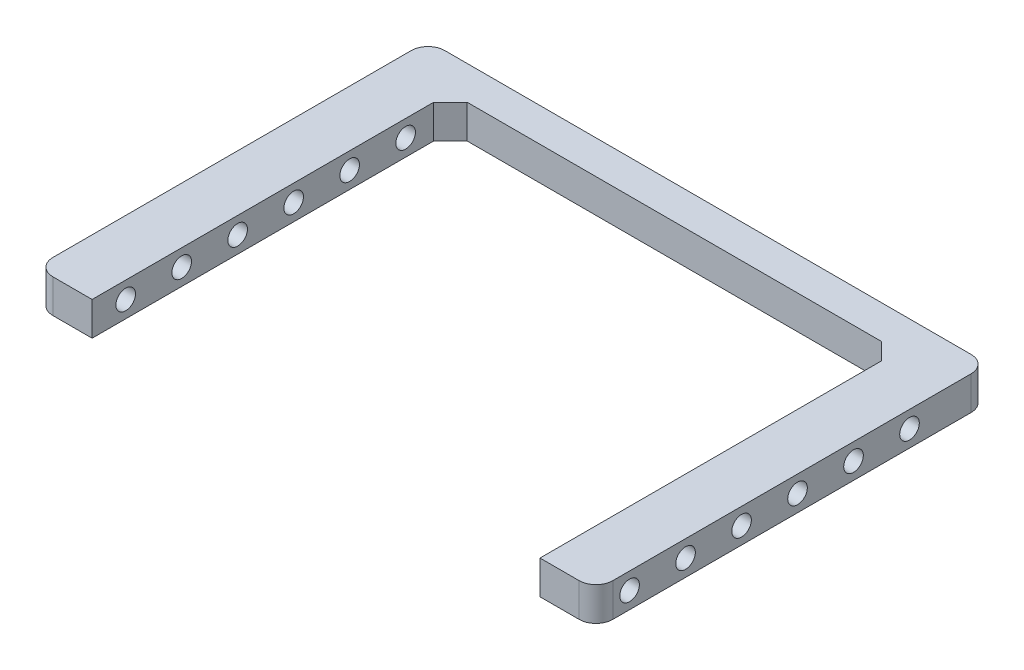
from build123d import *

# Parameters (mm, degrees)
BOSS_EXTRUDE1_DEPTH     = 3
SKETCH2_R               = 0.875
CUT_EXTRUDE1_DEPTH      = 51
CUT_EXTRUDE1_DEPTH_BACK = 3
FILLET2_R               = 1.5
CHAMFER1_SIZE           = 1.5


with BuildPart() as part:
    # Sketch1 → Boss-Extrude1 (new body)
    with BuildSketch(Plane(origin=(0, 0, 0), x_dir=(1, 0, 0), z_dir=(0, 1, 0))):
        Polygon((-25, -21), (-20, -21), (-20, 11), (20, 11), (20, -21), (25, -21), (25, 14), (-25, 14), align=None)
    extrude(amount=BOSS_EXTRUDE1_DEPTH)

    # Sketch2 → Cut-Extrude1 (cut, two sides)
    with BuildSketch(Plane.ZY.offset(-25)) as cut_extrude1_sk:
        with Locations((18, 1.5)):
            Circle(SKETCH2_R)
        with Locations((13, 1.5)):
            Circle(SKETCH2_R)
        with Locations((8, 1.5)):
            Circle(SKETCH2_R)
        with Locations((3, 1.5)):
            Circle(SKETCH2_R)
        with Locations((-2, 1.5)):
            Circle(SKETCH2_R)
        with Locations((-7, 1.5)):
            Circle(SKETCH2_R)
    extrude(amount=CUT_EXTRUDE1_DEPTH, mode=Mode.SUBTRACT)
    extrude(cut_extrude1_sk.sketch, amount=-CUT_EXTRUDE1_DEPTH_BACK, mode=Mode.SUBTRACT)

    # Fillet2
    fillet2_edges = [part.edges().sort_by_distance(p)[0] for p in [
        (25, 1.5, 21),
        (-25, 1.5, 21),
        (-25, 1.5, -14),
        (25, 1.5, -14),
    ]]
    fillet(fillet2_edges, radius=FILLET2_R)

    # Chamfer1
    chamfer1_edges = [part.edges().sort_by_distance(p)[0] for p in [
        (20, 1.5, -11),
        (-20, 1.5, -11),
    ]]
    chamfer(chamfer1_edges, length=CHAMFER1_SIZE)


solid = part.part
